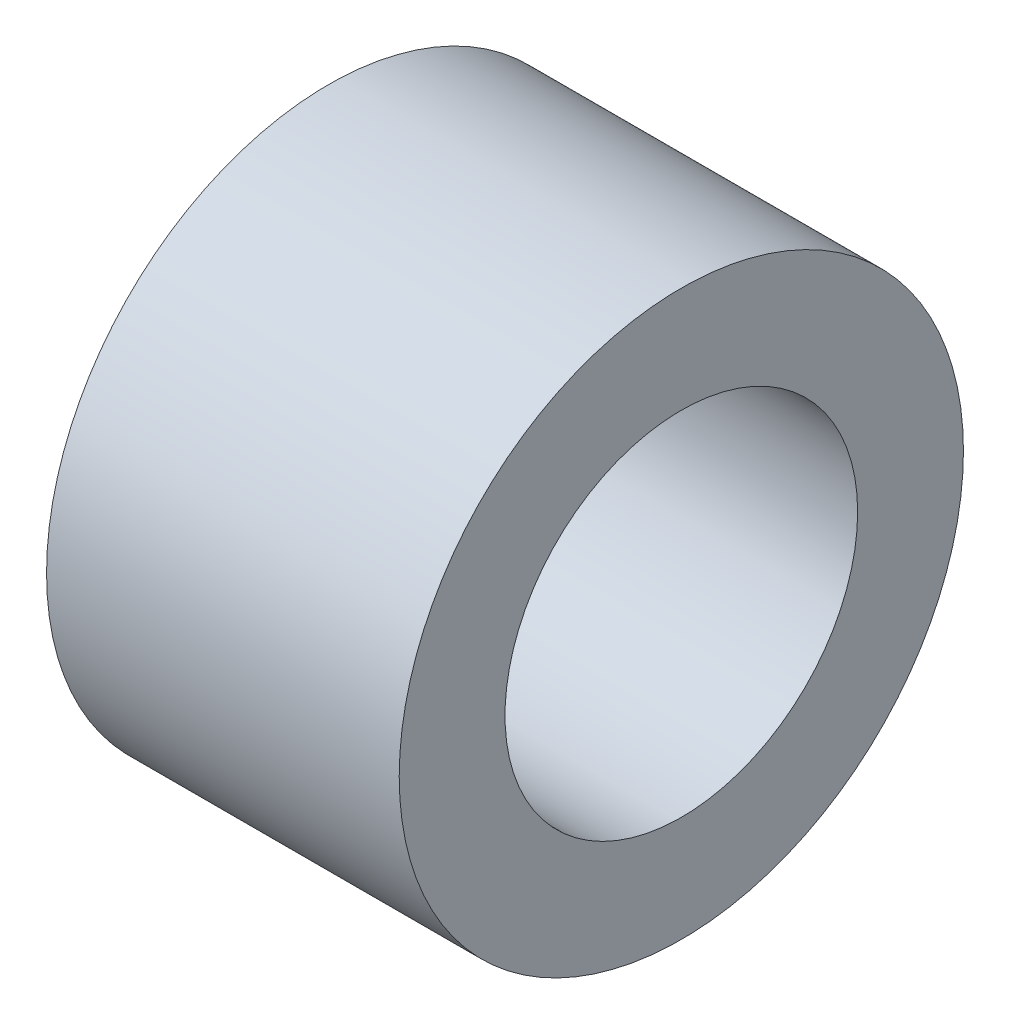
from build123d import *

# Parameters (mm, degrees)
SKETCH1_R           = 3.81
BOSS_EXTRUDE1_DEPTH = 4.7625
SKETCH2_R           = 2.38125
CUT_EXTRUDE1_DEPTH  = 5.7625


with BuildPart() as part:
    # Sketch1 → Boss-Extrude1 (new body)
    with BuildSketch(Plane(origin=(0, 0, 0), x_dir=(0, 0, -1), z_dir=(1, 0, 0))):
        Circle(SKETCH1_R)
    extrude(amount=BOSS_EXTRUDE1_DEPTH)

    # Sketch2 → Cut-Extrude1 (cut, through all)
    with BuildSketch(Plane(origin=(4.7625, 0, 0), x_dir=(0, 0, -1), z_dir=(1, 0, 0))):
        Circle(SKETCH2_R)
    extrude(amount=-CUT_EXTRUDE1_DEPTH, mode=Mode.SUBTRACT)


solid = part.part
